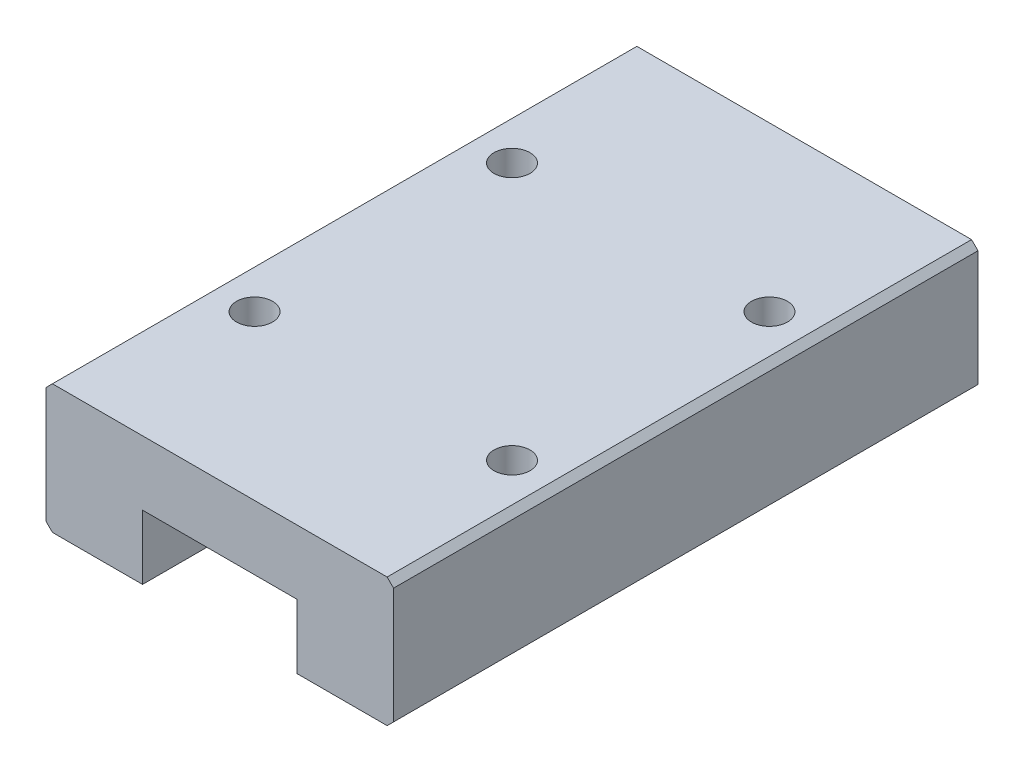
from build123d import *

# Parameters (mm, degrees)
EXTRUDE_1_DEPTH     = 45.4
HOLE_WIZARD_2_D     = 2.8
HOLE_WIZARD_2_DEPTH = 3.5


with BuildPart() as part:
    # 草图1 → 凸台-拉伸1 (new body)
    with BuildSketch(Plane.XY):
        Polygon((-1.576923077, 14.043956044), (24.423076923, 14.043956044), (24.923076923, 13.543956044), (24.923076923, 4.543956044), (24.423076923, 4.043956044), (17.423076923, 4.043956044), (17.423076923, 9.043956044), (5.423076923, 9.043956044), (5.423076923, 4.043956044), (-1.576923077, 4.043956044), (-2.076923077, 4.543956044), (-2.076923077, 13.543956044), align=None)
    extrude(amount=EXTRUDE_1_DEPTH)

    # 孔2
    with Locations(Plane(origin=(21.423076923, 14.043956044, 32.7), x_dir=(0, 0, 1), z_dir=(0, 1, 0))):
        with Locations((0, 0), (-20, 0), (-20, -20), (0, -20)):
            Hole(HOLE_WIZARD_2_D / 2, depth=HOLE_WIZARD_2_DEPTH)


solid = part.part
